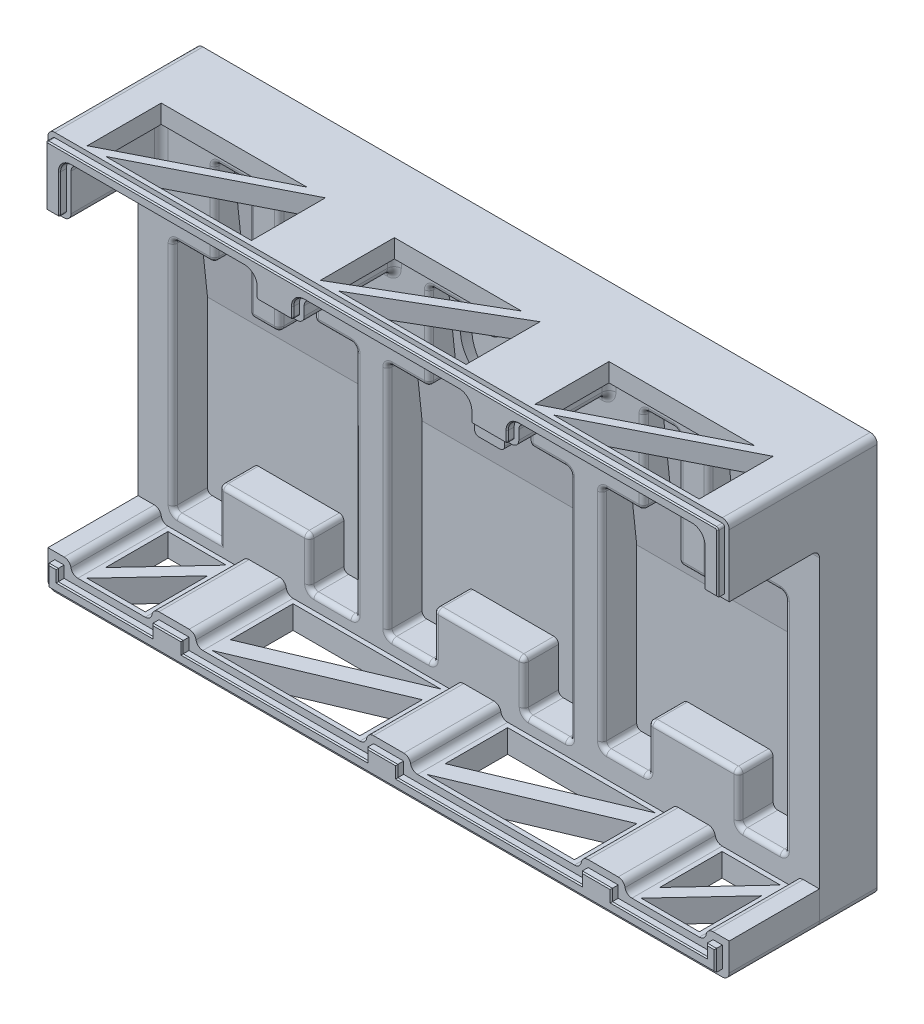
from build123d import *

# Parameters (mm, degrees)
SCHIZZO1_W                    = 294.6
SCHIZZO1_H                    = 172
ESTRUSIONE_ESTRUSIONE1_DEPTH  = 10
ESTRUSIONE_ESTRUSIONE2_DEPTH  = 15
ESTRUSIONE_ESTRUSIONE3_DEPTH  = 264.6
ESTRUSIONE_ESTRUSIONE4_DEPTH  = 39
RACCORDO1_R                   = 3
RACCORDO2_R                   = 2
RACCORDO4_R                   = 2
ESTRUSIONE_ESTRUSIONE5_DEPTH  = 39
RACCORDO8_R                   = 3
ESTRUSIONE_ESTRUSIONE6_DEPTH  = 3
TAGLIO_ESTRUSIONE1_DEPTH      = 4
RACCORDO9_R                   = 3
RACCORDO10_R                  = 3
RACCORDO11_R                  = 3
RACCORDO12_R                  = 3
RACCORDO13_R                  = 3
RACCORDO14_R                  = 3
SMUSSO1_SIZE                  = 0.5
SMUSSO2_SIZE                  = 0.5
TAGLIO_ESTRUSIONE2_DEPTH      = 10
TAGLIO_ESTRUSIONE3_DEPTH      = 10
RACCORDO15_R                  = 3
SCHIZZO15_W                   = 18.505881621
SCHIZZO15_H                   = 6.477058567
TAGLIO_ESTRUSIONE4_DEPTH      = 37
SCHIZZO16_R                   = 17.5
TAGLIO_ESTRUSIONE5_DEPTH      = 37
TAGLIO_ESTRUSIONE5_DEPTH_BACK = 10.35752


with BuildPart() as part:
    # Schizzo1 → Estrusione-Estrusione1 (new body)
    with BuildSketch(Plane.XY):
        Rectangle(SCHIZZO1_W, SCHIZZO1_H)
    extrude(amount=ESTRUSIONE_ESTRUSIONE1_DEPTH)

    # Schizzo2 → Estrusione-Estrusione2 (add)
    with BuildSketch(Plane.XY.offset(10)):
        Polygon((147.3, 86), (-147.3, 86), (-147.3, -86), (-6.32315089, -86), (147.3, -86), align=None)
        Polygon((-53.3, -70), (-73.3, -70), (-73.3, -49), (-112.3, -49), (-112.3, -70), (-132.3, -70), (-132.3, 32), (-114.3, 32), (-114.3, 70), (-99.3, 70), (-99.3, 20), (-86.3, 20), (-86.3, 70), (-71.3, 70), (-71.3, 32), (-53.3, 32), align=None, mode=Mode.SUBTRACT)
        Polygon((-39.5, -69.8088117), (-39.5, 32), (-21.5, 32), (-21.5, 70), (-6.5, 70), (-6.5, 20), (6.5, 20), (6.5, 70), (21.5, 70), (21.5, 32), (39.5, 32), (39.5, -69.8088117), (19.5, -69.8088117), (19.5, -48.8088117), (-19.5, -48.8088117), (-19.5, -69.8088117), align=None, mode=Mode.SUBTRACT)
        Polygon((53.3, -65.493311744), (53.3, 32), (71.3, 32), (71.3, 70), (86.3, 70), (86.3, 20), (99.3, 20), (99.3, 70), (114.3, 70), (114.3, 32), (132.3, 32), (132.3, -65.493311744), (112.3, -65.493311744), (112.3, -44.493311744), (73.3, -44.493311744), (73.3, -65.493311744), align=None, mode=Mode.SUBTRACT)
    extrude(amount=ESTRUSIONE_ESTRUSIONE2_DEPTH)

    # Schizzo4 → Estrusione-Estrusione3 (add)
    with BuildSketch(Plane.ZY.offset(-132.3)):
        Polygon((10, 70), (10, 3.34), (17.12, 70), align=None)
    extrude(amount=ESTRUSIONE_ESTRUSIONE3_DEPTH)

    # Schizzo5 → Estrusione-Estrusione4 (add)
    with BuildSketch(Plane.XY.offset(25)):
        Polygon((-147.3, 86), (-147.3, 56), (-137.3, 56), (-137.3, 78), (-56.3, 78), (-56.3, 68), (-36.5, 68), (-36.5, 78), (36.5, 78), (36.5, 68), (56.3, 68), (56.3, 78), (137.3, 78), (137.3, 56), (147.3, 56), (147.3, 86), align=None)
    extrude(amount=ESTRUSIONE_ESTRUSIONE4_DEPTH)

    # Raccordo1
    raccordo1_edges = [part.edges().sort_by_distance(p)[0] for p in [
        (-142.3, 56, 25),
        (-137.3, 67, 25),
        (-137.3, 56, 44.5),
        (-96.8, 78, 25),
        (-137.3, 78, 44.5),
        (-56.3, 73, 25),
        (-56.3, 78, 44.5),
        (-46.4, 68, 25),
        (-56.3, 68, 44.5),
        (-36.5, 73, 25),
        (-36.5, 68, 44.5),
        (0, 78, 25),
        (-36.5, 78, 44.5),
        (36.5, 73, 25),
        (36.5, 78, 44.5),
        (46.4, 68, 25),
        (36.5, 68, 44.5),
        (56.3, 73, 25),
        (56.3, 68, 44.5),
        (96.8, 78, 25),
        (56.3, 78, 44.5),
        (137.3, 67, 25),
        (137.3, 78, 44.5),
        (142.3, 56, 25),
        (137.3, 56, 44.5),
        (-147.3, 86, 32),
        (147.3, 86, 32),
    ]]
    fillet(raccordo1_edges, radius=RACCORDO1_R)

    # Raccordo2
    raccordo2_edges = [part.edges().sort_by_distance(p)[0] for p in [
        (-86.3, 45, 25),
        (-86.3, 20, 18.389732973),
        (-86.3, 70, 21.06),
        (-71.3, 70, 21.06),
        (-62.3, 32, 25),
        (-71.3, 32, 19.03059706),
        (-53.3, 32, 19.03059706),
        (-63.3, -70, 25),
        (-53.3, -70, 17.5),
        (-73.3, -59.5, 25),
        (-73.3, -70, 17.5),
        (-92.8, -49, 25),
        (-73.3, -49, 17.5),
        (-112.3, -49, 17.5),
        (-122.3, -70, 25),
        (-132.3, -19, 25),
        (-132.3, -70, 17.5),
        (-132.3, 32, 19.03059706),
        (-114.3, 51, 25),
        (-114.3, 32, 19.03059706),
        (-114.3, 70, 21.06),
        (-99.3, 70, 21.06),
        (-99.3, 20, 18.389732973),
        (-78.8, 70, 25),
        (-71.3, 51, 25),
        (-53.3, -19, 25),
        (-112.3, -59.5, 25),
        (-123.3, 32, 25),
        (-106.8, 70, 25),
        (-99.3, 45, 25),
        (-92.8, 20, 25),
    ]]
    fillet(raccordo2_edges, radius=RACCORDO2_R)

    # Raccordo4
    raccordo4_edges = [part.edges().sort_by_distance(p)[0] for p in [
        (86.3, 70, 21.06),
        (86.3, 20, 18.389732973),
        (99.3, 45, 25),
        (99.3, 20, 18.389732973),
        (99.3, 70, 21.06),
        (114.3, 70, 21.06),
        (123.3, 32, 25),
        (114.3, 32, 19.03059706),
        (132.3, 32, 19.03059706),
        (122.3, -65.493311744, 25),
        (132.3, -65.493311744, 17.5),
        (112.3, -54.993311744, 25),
        (112.3, -65.493311744, 17.5),
        (92.8, -44.493311744, 25),
        (112.3, -44.493311744, 17.5),
        (73.3, -44.493311744, 17.5),
        (63.3, -65.493311744, 25),
        (73.3, -65.493311744, 17.5),
        (53.3, -16.746655872, 25),
        (53.3, -65.493311744, 17.5),
        (53.3, 32, 19.03059706),
        (71.3, 51, 25),
        (71.3, 32, 19.03059706),
        (-6.5, 70, 21.06),
        (-6.5, 20, 18.389732973),
        (6.5, 45, 25),
        (6.5, 20, 18.389732973),
        (6.5, 70, 21.06),
        (21.5, 70, 21.06),
        (30.5, 32, 25),
        (21.5, 32, 19.03059706),
        (39.5, 32, 19.03059706),
        (29.5, -69.8088117, 25),
        (39.5, -69.8088117, 17.5),
        (19.5, -59.3088117, 25),
        (19.5, -69.8088117, 17.5),
        (0, -48.8088117, 25),
        (19.5, -48.8088117, 17.5),
        (-19.5, -48.8088117, 17.5),
        (-29.5, -69.8088117, 25),
        (-19.5, -69.8088117, 17.5),
        (-39.5, -18.90440585, 25),
        (-39.5, -69.8088117, 17.5),
        (-39.5, 32, 19.03059706),
        (-21.5, 51, 25),
        (-21.5, 32, 19.03059706),
        (-21.5, 70, 21.06),
        (71.3, 70, 21.06),
        (-6.5, 45, 25),
        (0, 20, 25),
        (14, 70, 25),
        (21.5, 51, 25),
        (39.5, -18.90440585, 25),
        (-19.5, -59.3088117, 25),
        (-30.5, 32, 25),
        (-14, 70, 25),
        (86.3, 45, 25),
        (92.8, 20, 25),
        (106.8, 70, 25),
        (114.3, 51, 25),
        (132.3, -16.746655872, 25),
        (73.3, -54.993311744, 25),
        (62.3, 32, 25),
        (78.8, 70, 25),
    ]]
    fillet(raccordo4_edges, radius=RACCORDO4_R)

    # Raccordo8
    raccordo8_edges = [part.edges().sort_by_distance(p)[0] for p in [
        (147.3, -86, 12.5),
        (-147.3, -86, 12.5),
    ]]
    fillet(raccordo8_edges, radius=RACCORDO8_R)

    # Schizzo10 → Estrusione-Estrusione6 (add)
    with BuildSketch(Plane.XY.offset(64)):
        with BuildLine():
            Line((-38.5, 71), (-38.5, 75))
            ThreePointArc((-38.5, 75), (-37.035533906, 78.535533906), (-33.5, 80))
            Line((-33.5, 80), (33.5, 80))
            ThreePointArc((33.5, 80), (37.035533906, 78.535533906), (38.5, 75))
            Line((38.5, 75), (38.5, 71))
            ThreePointArc((38.5, 71), (38.792893219, 70.292893219), (39.5, 70))
            Line((39.5, 70), (53.3, 70))
            ThreePointArc((53.3, 70), (54.007106781, 70.292893219), (54.3, 71))
            Line((54.3, 71), (54.3, 75))
            ThreePointArc((54.3, 75), (55.764466094, 78.535533906), (59.3, 80))
            Line((59.3, 80), (134.3, 80))
            ThreePointArc((134.3, 80), (137.835533906, 78.535533906), (139.3, 75))
            Line((139.3, 75), (139.3, 59))
            ThreePointArc((139.3, 59), (139.592893219, 58.292893219), (140.3, 58))
            Line((140.3, 58), (145.3, 58))
            Line((145.3, 58), (145.3, 83))
            ThreePointArc((145.3, 83), (145.007106781, 83.707106781), (144.3, 84))
            Line((144.3, 84), (-144.3, 84))
            ThreePointArc((-144.3, 84), (-145.007106781, 83.707106781), (-145.3, 83))
            Line((-145.3, 83), (-145.3, 58))
            Line((-145.3, 58), (-140.3, 58))
            ThreePointArc((-140.3, 58), (-139.592893219, 58.292893219), (-139.3, 59))
            Line((-139.3, 59), (-139.3, 75))
            ThreePointArc((-139.3, 75), (-137.835533906, 78.535533906), (-134.3, 80))
            Line((-134.3, 80), (-59.3, 80))
            ThreePointArc((-59.3, 80), (-55.764466094, 78.535533906), (-54.3, 75))
            Line((-54.3, 75), (-54.3, 71))
            ThreePointArc((-54.3, 71), (-54.007106781, 70.292893219), (-53.3, 70))
            Line((-53.3, 70), (-39.5, 70))
            ThreePointArc((-39.5, 70), (-38.792893219, 70.292893219), (-38.5, 71))
        make_face()
        Polygon((140.3, -74), (140.3, -79), (99.3, -79), (99.3, -74), (86.3, -74), (86.3, -79), (6.5, -79), (6.5, -74), (-6.5, -74), (-6.5, -79), (-86.3, -79), (-86.3, -74), (-99.3, -74), (-99.3, -79), (-140.3, -79), (-140.3, -74), (-144.3, -74), (-144.3, -83), (144.3, -83), (144.3, -74), align=None)
    extrude(amount=ESTRUSIONE_ESTRUSIONE6_DEPTH)

    # Schizzo11 → Taglio-Estrusione1 (cut)
    with BuildSketch(Plane.XY):
        with BuildLine():
            Line((-144.3, -83), (144.3, -83))
            Line((144.3, -83), (144.3, -74))
            Line((144.3, -74), (140.3, -74))
            ThreePointArc((140.3, -74), (138.256903563, -77.582575695), (134.383920217, -79))
            Line((134.383920217, -79), (107.216079783, -79))
            ThreePointArc((107.216079783, -79), (103.343096437, -77.582575695), (101.3, -74))
            Line((101.3, -74), (84.3, -74))
            ThreePointArc((84.3, -74), (82.256903563, -77.582575695), (78.383920217, -79))
            Line((78.383920217, -79), (14.416079783, -79))
            ThreePointArc((14.416079783, -79), (10.543096437, -77.582575695), (8.5, -74))
            Line((8.5, -74), (-8.5, -74))
            ThreePointArc((-8.5, -74), (-10.543096437, -77.582575695), (-14.416079783, -79))
            Line((-14.416079783, -79), (-78.383920217, -79))
            ThreePointArc((-78.383920217, -79), (-82.256903563, -77.582575695), (-84.3, -74))
            Line((-84.3, -74), (-101.3, -74))
            ThreePointArc((-101.3, -74), (-103.343096437, -77.582575695), (-107.216079783, -79))
            Line((-107.216079783, -79), (-134.383920217, -79))
            ThreePointArc((-134.383920217, -79), (-138.256903563, -77.582575695), (-140.3, -74))
            Line((-140.3, -74), (-144.3, -74))
            Line((-144.3, -74), (-144.3, -83))
        make_face()
        with BuildLine():
            Line((140.3, 58), (144.3, 58))
            ThreePointArc((144.3, 58), (145.007106781, 58.292893219), (145.3, 59))
            Line((145.3, 59), (145.3, 83))
            ThreePointArc((145.3, 83), (145.007106781, 83.707106781), (144.3, 84))
            Line((144.3, 84), (-144.3, 84))
            ThreePointArc((-144.3, 84), (-145.007106781, 83.707106781), (-145.3, 83))
            Line((-145.3, 83), (-145.3, 59))
            ThreePointArc((-145.3, 59), (-145.007106781, 58.292893219), (-144.3, 58))
            Line((-144.3, 58), (-140.3, 58))
            ThreePointArc((-140.3, 58), (-139.592893219, 58.292893219), (-139.3, 59))
            Line((-139.3, 59), (-139.3, 75))
            ThreePointArc((-139.3, 75), (-137.835533906, 78.535533906), (-134.3, 80))
            Line((-134.3, 80), (-59.3, 80))
            ThreePointArc((-59.3, 80), (-55.764466094, 78.535533906), (-54.3, 75))
            Line((-54.3, 75), (-54.3, 71))
            ThreePointArc((-54.3, 71), (-54.007106781, 70.292893219), (-53.3, 70))
            Line((-53.3, 70), (-39.5, 70))
            ThreePointArc((-39.5, 70), (-38.792893219, 70.292893219), (-38.5, 71))
            Line((-38.5, 71), (-38.5, 75))
            ThreePointArc((-38.5, 75), (-37.035533906, 78.535533906), (-33.5, 80))
            Line((-33.5, 80), (33.5, 80))
            ThreePointArc((33.5, 80), (37.035533906, 78.535533906), (38.5, 75))
            Line((38.5, 75), (38.5, 71))
            ThreePointArc((38.5, 71), (38.792893219, 70.292893219), (39.5, 70))
            Line((39.5, 70), (53.3, 70))
            ThreePointArc((53.3, 70), (54.007106781, 70.292893219), (54.3, 71))
            Line((54.3, 71), (54.3, 75))
            ThreePointArc((54.3, 75), (55.764466094, 78.535533906), (59.3, 80))
            Line((59.3, 80), (134.3, 80))
            ThreePointArc((134.3, 80), (137.835533906, 78.535533906), (139.3, 75))
            Line((139.3, 75), (139.3, 59))
            ThreePointArc((139.3, 59), (139.592893219, 58.292893219), (140.3, 58))
        make_face()
    extrude(amount=TAGLIO_ESTRUSIONE1_DEPTH, mode=Mode.SUBTRACT)

    # Smusso1
    smusso1_edges = [part.edges().sort_by_distance(p)[0] for p in [
        (119.8, -79, 67),
        (99.3, -76.5, 67),
        (92.8, -74, 67),
        (86.3, -76.5, 67),
        (46.4, -79, 67),
        (6.5, -76.5, 67),
        (0, -74, 67),
        (-6.5, -76.5, 67),
        (-46.4, -79, 67),
        (-86.3, -76.5, 67),
        (142.3, -74, 67),
        (-92.8, -74, 67),
        (-99.3, -76.5, 67),
        (-119.8, -79, 67),
        (-140.3, -76.5, 67),
        (-142.3, -74, 67),
        (-144.3, -78.5, 67),
        (0, -83, 67),
        (144.3, -78.5, 67),
        (140.3, -76.5, 67),
    ]]
    chamfer(smusso1_edges, length=SMUSSO1_SIZE)

    # Smusso2
    smusso2_edges = [part.edges().sort_by_distance(p)[0] for p in [
        (145.3, 70.5, 67),
        (145.007106781, 83.707106781, 67),
        (0, 84, 67),
        (-145.007106781, 83.707106781, 67),
        (-145.3, 70.5, 67),
        (-142.8, 58, 67),
        (-139.592893219, 58.292893219, 67),
        (-139.3, 67, 67),
        (-137.835533906, 78.535533906, 67),
        (-96.8, 80, 67),
        (-55.764466094, 78.535533906, 67),
        (-54.3, 73, 67),
        (-54.007106781, 70.292893219, 67),
        (-46.4, 70, 67),
        (-38.792893219, 70.292893219, 67),
        (-38.5, 73, 67),
        (-37.035533906, 78.535533906, 67),
        (0, 80, 67),
        (37.035533906, 78.535533906, 67),
        (38.5, 73, 67),
        (38.792893219, 70.292893219, 67),
        (46.4, 70, 67),
        (54.007106781, 70.292893219, 67),
        (54.3, 73, 67),
        (55.764466094, 78.535533906, 67),
        (96.8, 80, 67),
        (137.835533906, 78.535533906, 67),
        (139.3, 67, 67),
        (139.592893219, 58.292893219, 67),
        (142.8, 58, 67),
    ]]
    chamfer(smusso2_edges, length=SMUSSO2_SIZE)

    # Schizzo12 → Taglio-Estrusione2 (cut)
    with BuildSketch(Plane.XZ.offset(-78)):
        Polygon((-132.3, 30), (-132.3, 62), (-69.3, 30), align=None)
        Polygon((-124.3, 62), (-61.3, 62), (-61.3, 30), align=None)
        Polygon((132.3, 62), (132.3, 30), (69.3, 62), align=None)
        Polygon((61.3, 62), (124.3, 30), (61.3, 30), align=None)
        Polygon((-31.5, 30), (23.5, 30), (-31.5, 62), align=None)
        Polygon((-23.5, 62), (31.5, 62), (31.5, 30), align=None)
    extrude(amount=-TAGLIO_ESTRUSIONE2_DEPTH, mode=Mode.SUBTRACT)

    # Schizzo15 → Taglio-Estrusione4 (cut)
    with BuildSketch(Plane.XZ.offset(-20)):
        with Locations((0.42892632, 23.596048806)):
            Rectangle(SCHIZZO15_W, SCHIZZO15_H)
    extrude(amount=-TAGLIO_ESTRUSIONE4_DEPTH, mode=Mode.SUBTRACT)

    # Schizzo16 → Taglio-Estrusione5 (cut, two sides)
    with BuildSketch(Plane.XY.offset(20.357519522)) as taglio_estrusione5_sk:
        with Locations((-0.5, 48.5)):
            Circle(SCHIZZO16_R)
    extrude(amount=TAGLIO_ESTRUSIONE5_DEPTH, mode=Mode.SUBTRACT)
    extrude(taglio_estrusione5_sk.sketch, amount=-TAGLIO_ESTRUSIONE5_DEPTH_BACK, mode=Mode.SUBTRACT)


with BuildPart() as body_2:
    # Schizzo8 → Estrusione-Estrusione5 (new body)
    with BuildSketch(Plane.XY.offset(25)):
        Polygon((-147.3, -86), (-147.3, -71), (-137.3, -71), (-137.3, -76), (-102.3, -76), (-102.3, -71), (-83.3, -71), (-83.3, -76), (-9.5, -76), (-9.5, -71), (9.5, -71), (9.5, -76), (83.3, -76), (83.3, -71), (102.3, -71), (102.3, -76), (137.3, -76), (137.3, -71), (147.3, -71), (147.3, -86), align=None)
    extrude(amount=ESTRUSIONE_ESTRUSIONE5_DEPTH)

    # Raccordo9
    raccordo9_edges = [body_2.edges().sort_by_distance(p)[0] for p in [
        (9.5, -76, 44.5),
        (-9.5, -71, 44.5),
        (-83.3, -76, 44.5),
        (-102.3, -71, 44.5),
    ]]
    fillet(raccordo9_edges, radius=RACCORDO9_R)

    # Raccordo10
    raccordo10_edges = [body_2.edges().sort_by_distance(p)[0] for p in [
        (-9.5, -76, 44.5),
        (-137.3, -71, 44.5),
        (-83.3, -71, 44.5),
        (-102.3, -76, 44.5),
    ]]
    fillet(raccordo10_edges, radius=RACCORDO10_R)

    # Raccordo11
    raccordo11_edges = [body_2.edges().sort_by_distance(p)[0] for p in [
        (-137.3, -76, 44.5),
        (137.3, -71, 44.5),
    ]]
    fillet(raccordo11_edges, radius=RACCORDO11_R)

    # Raccordo12
    raccordo12_edges = [body_2.edges().sort_by_distance(p)[0] for p in [
        (137.3, -76, 44.5),
        (102.3, -71, 44.5),
    ]]
    fillet(raccordo12_edges, radius=RACCORDO12_R)

    # Raccordo13
    raccordo13_edges = [body_2.edges().sort_by_distance(p)[0] for p in [
        (102.3, -76, 44.5),
        (9.5, -71, 44.5),
        (83.3, -71, 44.5),
    ]]
    fillet(raccordo13_edges, radius=RACCORDO13_R)

    # Raccordo14
    raccordo14_edges = [body_2.edges().sort_by_distance(p)[0] for p in [
        (-147.3, -86, 44.5),
        (147.3, -86, 44.5),
    ]]
    fillet(raccordo14_edges, radius=RACCORDO14_R)

    # Schizzo14 → Taglio-Estrusione3 (cut)
    with BuildSketch(Plane(origin=(0, -76, 0), x_dir=(1, 0, 0), z_dir=(0, 1, 0))):
        Polygon((-78.3, -27), (-14.416079783, -27), (-78.3, -54), align=None)
        Polygon((-78.3, -62), (-14.416079783, -35), (-14.416079783, -62), align=None)
        Polygon((78.383920217, -62), (14.5, -62), (78.383920217, -35), align=None)
        Polygon((78.383920217, -27), (14.5, -54), (14.5, -27), align=None)
        Polygon((107.216079783, -27), (132.383920217, -27), (107.216079783, -54), align=None)
        Polygon((132.383920217, -35), (132.383920217, -62), (107.216079783, -62), align=None)
        Polygon((-132.383920217, -27), (-107.216079783, -27), (-132.383920217, -54), align=None)
        Polygon((-132.383920217, -62), (-107.216079783, -35), (-107.216079783, -62), align=None)
    extrude(amount=-TAGLIO_ESTRUSIONE3_DEPTH, mode=Mode.SUBTRACT)

    # Raccordo15
    raccordo15_edges = [body_2.edges().sort_by_distance(p)[0] for p in [
        (83.3, -76, 44.5),
    ]]
    fillet(raccordo15_edges, radius=RACCORDO15_R)


solid = Compound([part.part, body_2.part])
